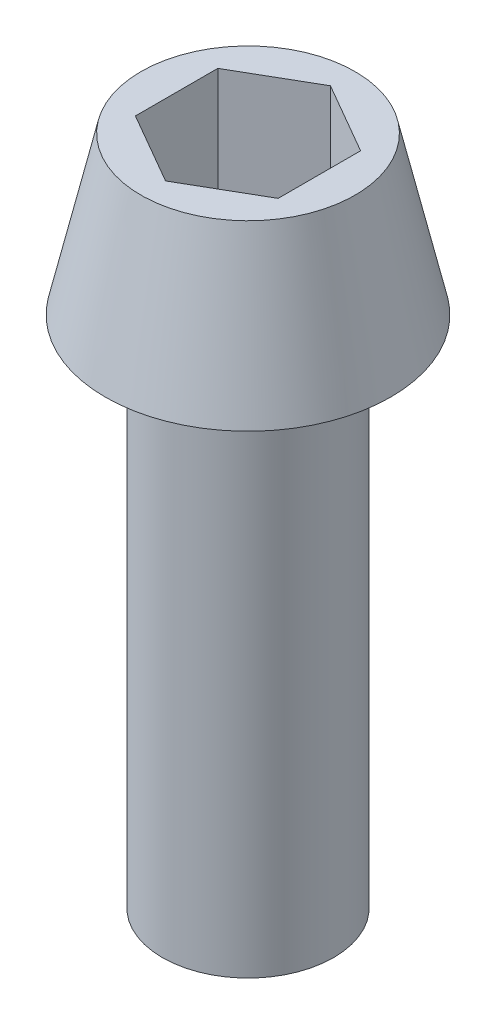
from build123d import *

# Parameters (mm, degrees)
ENL_V_MAT_EXTRU_1_DEPTH = 4


with BuildPart() as part:
    # Esquisse1 → Révolution1 (revolve)
    with BuildSketch(Plane.XY):
        Polygon((0, -18), (0, 5.5), (-3.75, 5.5), (-5, 0), (-3, 0), (-3, -18), align=None)
    revolve(axis=Axis((0, 21.133068783, 0), (0, -1, 0)))

    # Esquisse2 → Enlèv. mat.-Extru.1 (cut)
    with BuildSketch(Plane(origin=(0, 5.5, 0), x_dir=(-1, 0, 0), z_dir=(0, 1, 0))):
        Polygon((0, -2.886751346), (2.5, -1.443375673), (2.5, 1.443375673), (0, 2.886751346), (-2.5, 1.443375673), (-2.5, -1.443375673), align=None)
    extrude(amount=-ENL_V_MAT_EXTRU_1_DEPTH, mode=Mode.SUBTRACT)


solid = part.part
